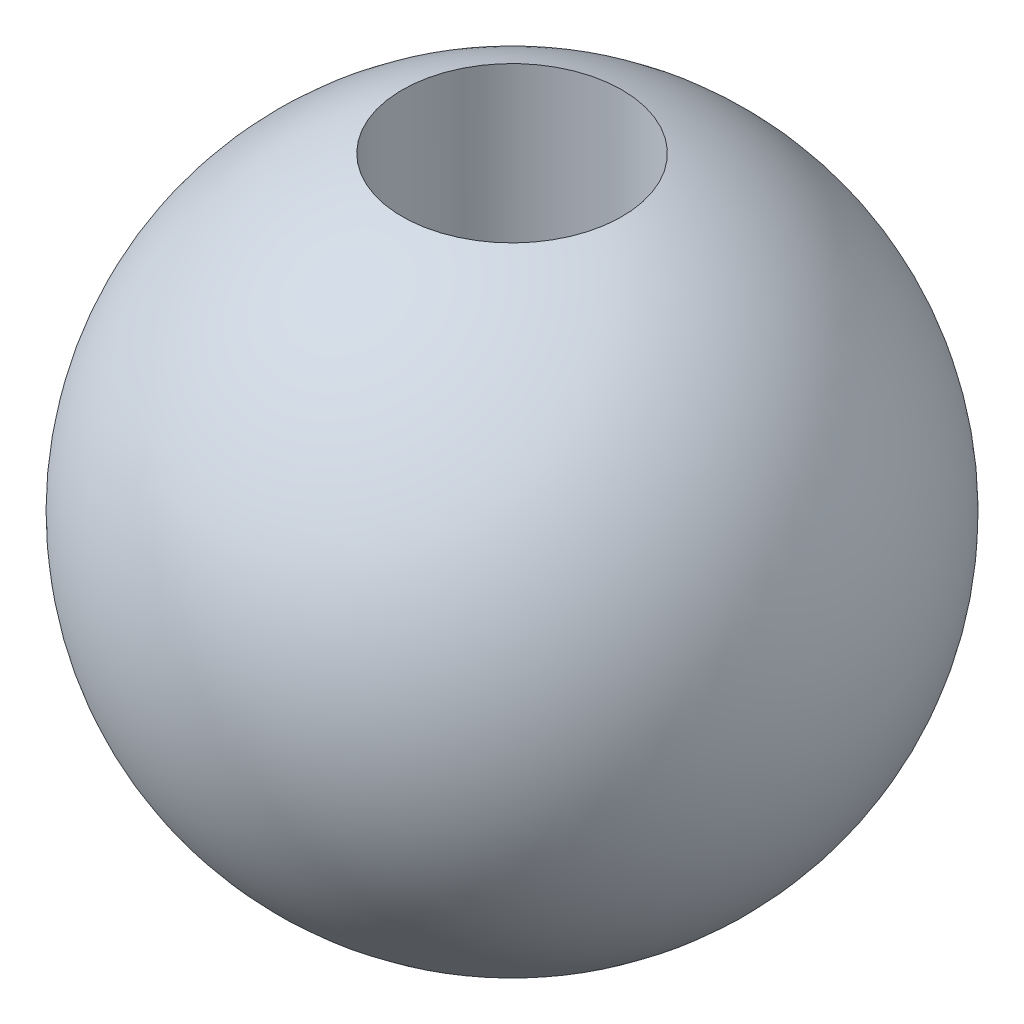
from build123d import *

# Parameters (mm, degrees)
SKETCH_2_R               = 1
CUT_EXTRUDE_1_DEPTH      = 4
CUT_EXTRUDE_1_DEPTH_BACK = 4


with BuildPart() as part:
    # 草图1 → 旋转3 (revolve)
    with BuildSketch(Plane(origin=(0, 0, 0), x_dir=(0, 0, -1), z_dir=(1, 0, 0))):
        with BuildLine():
            Line((0, 3), (0, -3))
            ThreePointArc((0, -3), (3, 0), (0, 3))
        make_face()
    revolve(axis=Axis((0, 3, 0), (0, -1, 0)))

    # 草图2 → 切除-拉伸1 (cut, two sides)
    with BuildSketch(Plane(origin=(0, 0, 0), x_dir=(1, 0, 0), z_dir=(0, 1, 0))) as cut_extrude_1_sk:
        Circle(SKETCH_2_R)
    extrude(amount=CUT_EXTRUDE_1_DEPTH, mode=Mode.SUBTRACT)
    extrude(cut_extrude_1_sk.sketch, amount=-CUT_EXTRUDE_1_DEPTH_BACK, mode=Mode.SUBTRACT)


solid = part.part
